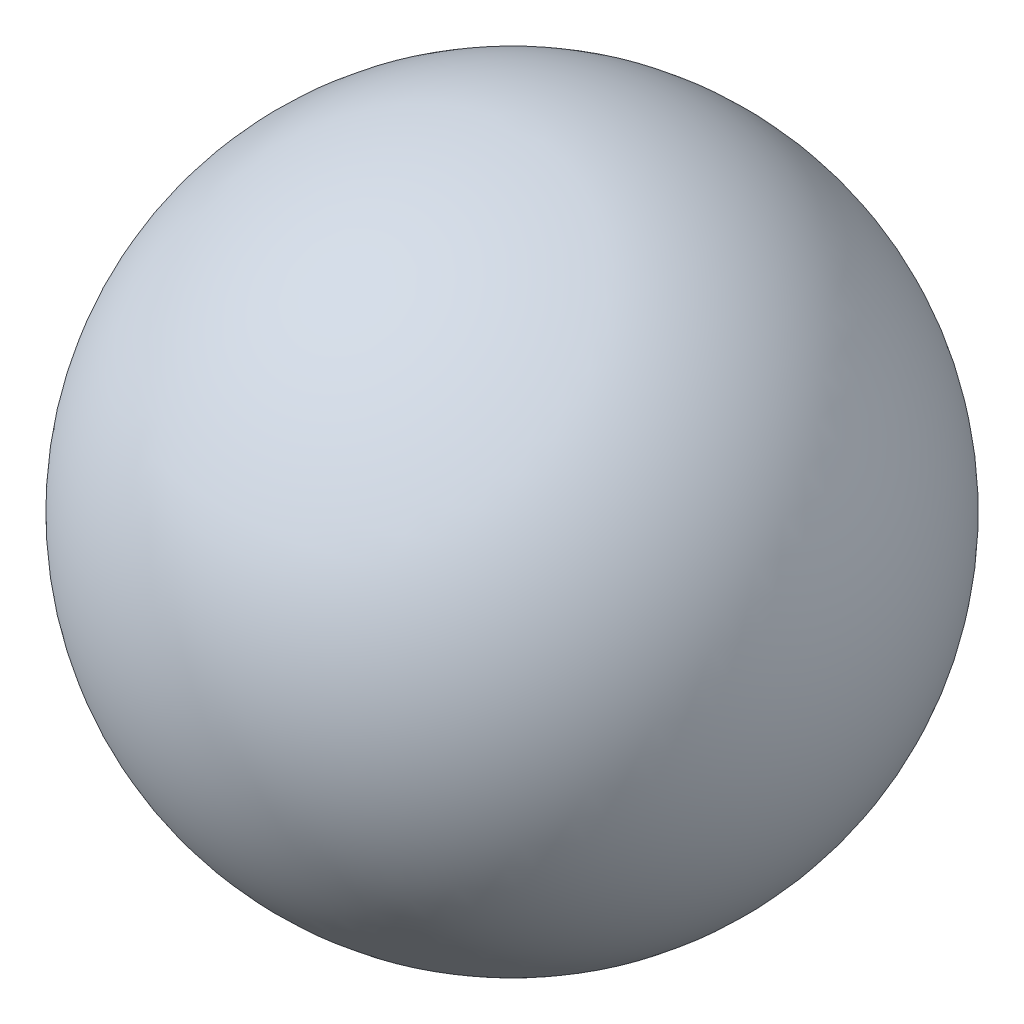
from build123d import *

# Parameters (mm, degrees)
AUFSATZ_LINEAR_AUSTRAGEN1_DEPTH = 2.5


with BuildPart() as part:
    # Skizze1 → Aufsatz-Linear austragen1 (new body, symmetric)
    with BuildSketch(Plane.XY):
        with BuildLine():
            Line((1.875, -1.25), (0, -1.25))
            Line((0, -1.25), (-1.875, -1.25))
            ThreePointArc((-1.875, -1.25), (-5, 1.875), (-1.875, 5))
            Line((-1.875, 5), (5, 5))
            Line((5, 5), (5, 2.5))
            Line((5, 2.5), (-1.875, 2.5))
            ThreePointArc((-1.875, 2.5), (-2.5, 1.875), (-1.875, 1.25))
            Line((-1.875, 1.25), (0, 1.25))
            Line((0, 1.25), (1.875, 1.25))
            ThreePointArc((1.875, 1.25), (5, -1.875), (1.875, -5))
            Line((1.875, -5), (-5, -5))
            Line((-5, -5), (-5, -2.5))
            Line((-5, -2.5), (1.875, -2.5))
            ThreePointArc((1.875, -2.5), (2.5, -1.875), (1.875, -1.25))
        make_face()
    extrude(amount=AUFSATZ_LINEAR_AUSTRAGEN1_DEPTH, both=True)


with BuildPart() as body_2:
    # Skizze2 → Rotation1 (revolve)
    with BuildSketch(Plane.XY):
        with BuildLine():
            Line((0, 10), (0, -10))
            ThreePointArc((0, -10), (-10, 0), (0, 10))
        make_face()
    revolve(axis=Axis((0, 10, 0), (0, -1, 0)))


solid = Compound([part.part, body_2.part])
